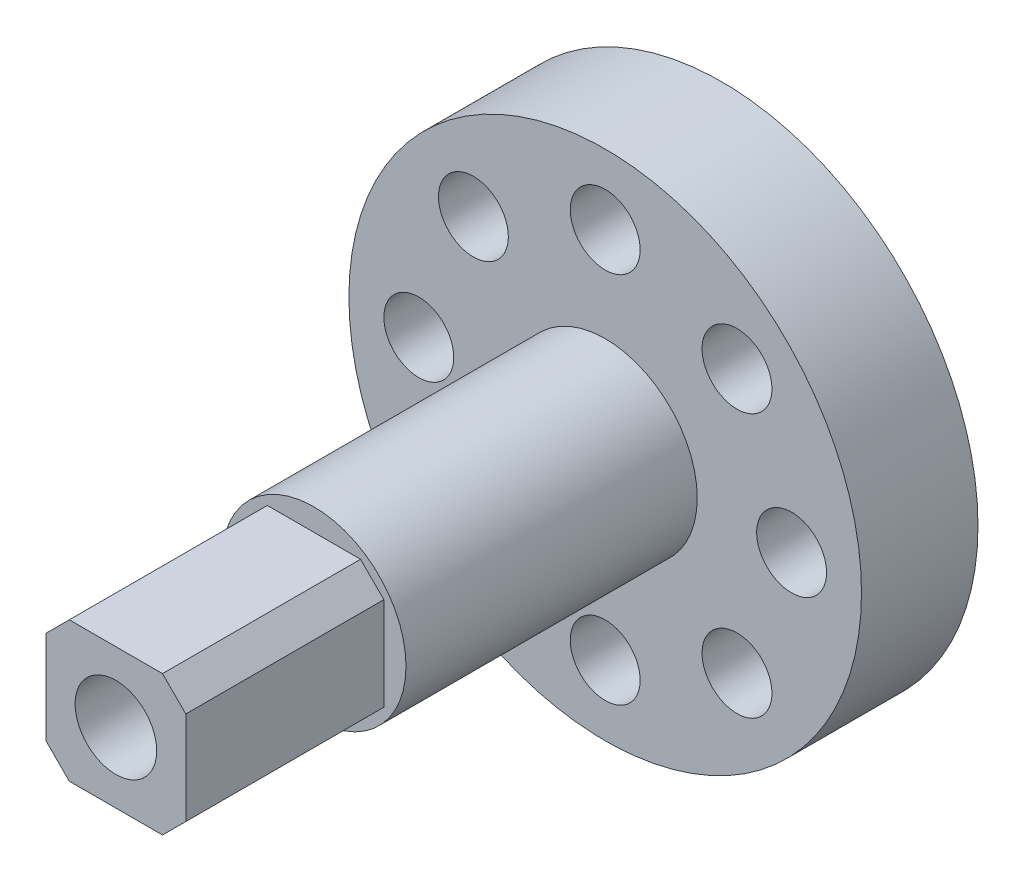
from build123d import *

# Parameters (mm, degrees)
ESQUISSE1_R                  = 11
ESQUISSE1_R_2                = 4.5
BOSS_EXTRU_1_DEPTH           = 4
ESQUISSE4_R                  = 11
BOSS_EXTRU_2_DEPTH           = 1
ESQUISSE2_R                  = 1.5
ENL_V_MAT_EXTRU_1_DEPTH      = 1
ENL_V_MAT_EXTRU_1_DEPTH_BACK = 6
ESQUISSE5_W                  = 6
ESQUISSE5_H                  = 6
BOSS_EXTRU_3_DEPTH           = 21
CHANFREIN1_SIZE              = 1
ESQUISSE8_R                  = 3.95
BOSS_EXTRU_4_DEPTH           = 12.5
ESQUISSE6_R                  = 1.75
ENL_V_MAT_EXTRU_2_DEPTH      = 1
ENL_V_MAT_EXTRU_2_DEPTH_BACK = 27


with BuildPart() as part:
    # Esquisse1 → Boss.-Extru.1 (new body)
    with BuildSketch(Plane.XY):
        Circle(ESQUISSE1_R)
        Circle(ESQUISSE1_R_2, mode=Mode.SUBTRACT)
    extrude(amount=BOSS_EXTRU_1_DEPTH)

    # Esquisse4 → Boss.-Extru.2 (add)
    with BuildSketch(Plane.XY.offset(4)):
        Circle(ESQUISSE4_R)
    extrude(amount=BOSS_EXTRU_2_DEPTH)

    # Esquisse2 → Enlèv. mat.-Extru.1 (cut, two sides)
    with BuildSketch(Plane.XY.offset(5)) as enl_v_mat_extru_1_sk:
        with Locations((8, 0)):
            Circle(ESQUISSE2_R)
        with Locations((5.656854249, -5.656854249)):
            Circle(ESQUISSE2_R)
        with Locations((0, -8)):
            Circle(ESQUISSE2_R)
        with Locations((-5.656854249, -5.656854249)):
            Circle(ESQUISSE2_R)
        with Locations((-8, 0)):
            Circle(ESQUISSE2_R)
        with Locations((-5.656854249, 5.656854249)):
            Circle(ESQUISSE2_R)
        with Locations((0, 8)):
            Circle(ESQUISSE2_R)
        with Locations((5.656854249, 5.656854249)):
            Circle(ESQUISSE2_R)
    extrude(amount=ENL_V_MAT_EXTRU_1_DEPTH, mode=Mode.SUBTRACT)
    extrude(enl_v_mat_extru_1_sk.sketch, amount=-ENL_V_MAT_EXTRU_1_DEPTH_BACK, mode=Mode.SUBTRACT)

    # Esquisse5 → Boss.-Extru.3 (add)
    with BuildSketch(Plane.XY.offset(5)):
        Rectangle(ESQUISSE5_W, ESQUISSE5_H)
    extrude(amount=BOSS_EXTRU_3_DEPTH)

    # Chanfrein1
    chanfrein1_edges = [part.edges().sort_by_distance(p)[0] for p in [
        (-3, 3, 15.5),
        (-3, -3, 15.5),
        (3, -3, 15.5),
        (3, 3, 15.5),
    ]]
    chamfer(chanfrein1_edges, length=CHANFREIN1_SIZE)

    # Esquisse8 → Boss.-Extru.4 (add)
    with BuildSketch(Plane.XY.offset(5)):
        Circle(ESQUISSE8_R)
    extrude(amount=BOSS_EXTRU_4_DEPTH)

    # Esquisse6 → Enlèv. mat.-Extru.2 (cut, two sides)
    with BuildSketch(Plane.XY.offset(26)) as enl_v_mat_extru_2_sk:
        Circle(ESQUISSE6_R)
    extrude(amount=ENL_V_MAT_EXTRU_2_DEPTH, mode=Mode.SUBTRACT)
    extrude(enl_v_mat_extru_2_sk.sketch, amount=-ENL_V_MAT_EXTRU_2_DEPTH_BACK, mode=Mode.SUBTRACT)


solid = part.part
